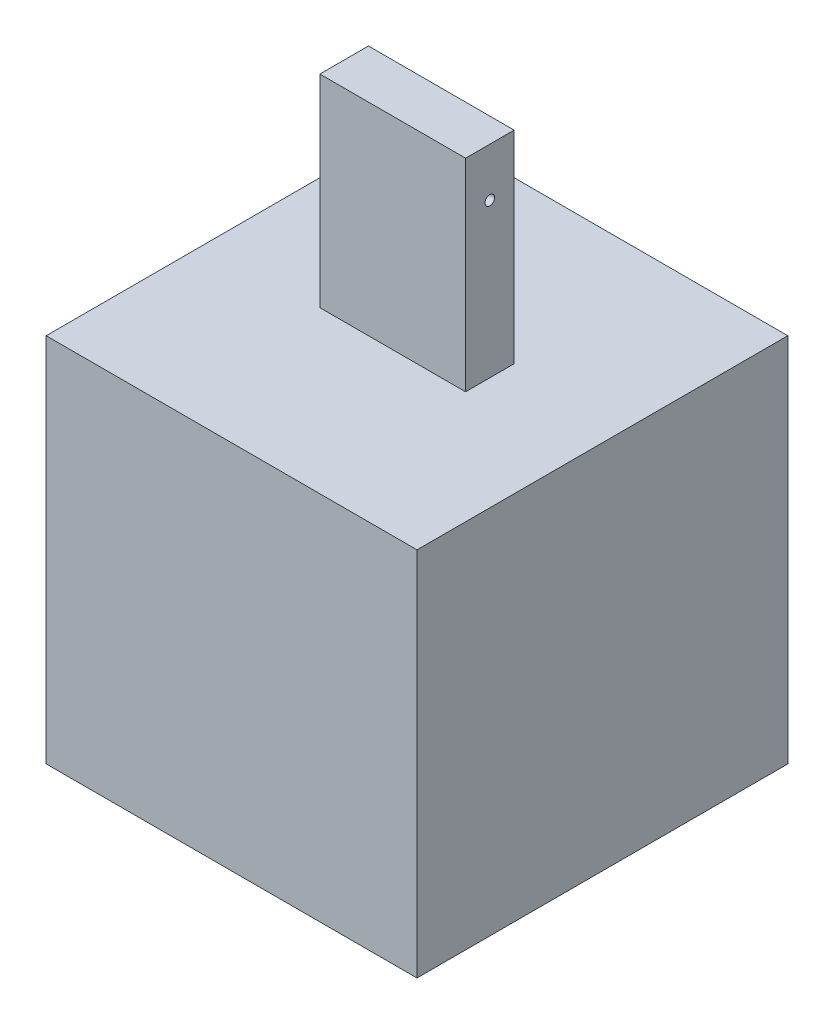
from build123d import *

# Parameters (mm, degrees)
IZIM1_W                     = 458.13
IZIM1_H                     = 458.13
Y_KSEKLIK_EKSTR_ZYON1_DEPTH = 458.13
IZIM2_W                     = 180
IZIM2_H                     = 60
Y_KSEKLIK_EKSTR_ZYON2_DEPTH = 250
IZIM3_R                     = 6
KES_EKSTR_ZYON1_DEPTH       = 299


with BuildPart() as part:
    # Çizim1 → Yükseklik-Ekstrüzyon1 (new body)
    with BuildSketch(Plane.XY):
        with Locations((229.065, 229.065)):
            Rectangle(IZIM1_W, IZIM1_H)
    extrude(amount=Y_KSEKLIK_EKSTR_ZYON1_DEPTH)


with BuildPart() as body_2:
    # Çizim2 → Yükseklik-Ekstrüzyon2 (new body)
    with BuildSketch(Plane(origin=(0, 458.13, 0), x_dir=(1, 0, 0), z_dir=(0, 1, 0))):
        with Locations((229.065, -229.065)):
            Rectangle(IZIM2_W, IZIM2_H)
    extrude(amount=Y_KSEKLIK_EKSTR_ZYON2_DEPTH)

    # Çizim3 → Kes-Ekstrüzyon1 (cut)
    with BuildSketch(Plane.ZY.offset(-139.065)):
        with Locations((229.065, 648.13)):
            Circle(IZIM3_R)
    extrude(amount=-KES_EKSTR_ZYON1_DEPTH, mode=Mode.SUBTRACT)


solid = Compound([part.part, body_2.part])
